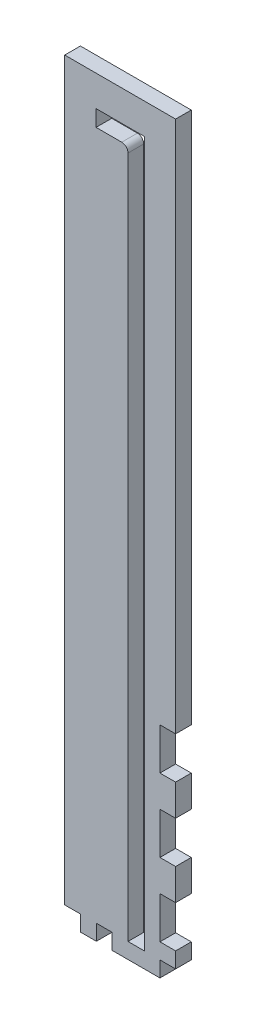
from build123d import *

# Parameters (mm, degrees)
SKETCH1_W           = 44.958
SKETCH1_H           = 304.8
BOSS_EXTRUDE1_DEPTH = 6.35
SKETCH2_W           = 6.35
SKETCH2_H           = 101.6
BOSS_EXTRUDE2_DEPTH = 6.35
SKETCH3_W           = 222.25
SKETCH3_H           = 6.35
BOSS_EXTRUDE3_DEPTH = 38.608
SKETCH7_W           = 327.022738736
SKETCH7_H           = 279.435650021
CUT_EXTRUDE1_DEPTH  = 45.958
SKETCH4_W           = 6.35
SKETCH4_H           = 6.35
SKETCH4_H_2         = 12.7
CUT_EXTRUDE2_DEPTH  = 6.35
SKETCH6_W           = 6.35
SKETCH6_H           = 16.933333333
SKETCH6_H_2         = 16.933333334
CUT_EXTRUDE3_DEPTH  = 7.35


with BuildPart() as part:
    # Sketch1 → Boss-Extrude1 (new body)
    with BuildSketch(Plane.XY):
        with Locations((-6.477, 3.048)):
            Rectangle(SKETCH1_W, SKETCH1_H)
        with BuildLine():
            Line((-3.302, 133.858), (-3.302, -143.002))
            Line((-3.302, -143.002), (3.302, -143.002))
            Line((3.302, -143.002), (3.302, 143.002))
            Line((3.302, 143.002), (-16.256, 143.002))
            Line((-16.256, 143.002), (-16.256, 136.398))
            Line((-16.256, 136.398), (-5.842, 136.398))
            ThreePointArc((-5.842, 136.398), (-4.045948776, 135.654051224), (-3.302, 133.858))
        make_face(mode=Mode.SUBTRACT)
    extrude(amount=BOSS_EXTRUDE1_DEPTH)

    # Sketch2 → Boss-Extrude2 (add)
    with BuildSketch(Plane(origin=(16.002, 0, 0), x_dir=(0, 0, -1), z_dir=(1, 0, 0))):
        Polygon((222.25, -60.452), (222.25, -47.752), (0, -47.752), (0, -149.352), (222.25, -149.352), (222.25, -136.652), (228.6, -136.652), (228.6, -119.718666667), (222.25, -119.718666667), (222.25, -107.018666667), (228.6, -107.018666667), (228.6, -90.085333333), (222.25, -90.085333333), (222.25, -77.385333333), (228.6, -77.385333333), (228.6, -60.452), align=None)
        with BuildLine():
            ThreePointArc((11.4, -116.592), (9.9, -118.092), (8.4, -116.592))
            Line((8.4, -116.592), (8.4, -111.512))
            ThreePointArc((8.4, -111.512), (9.9, -110.012), (11.4, -111.512))
            Line((11.4, -111.512), (11.4, -116.592))
        make_face(mode=Mode.SUBTRACT)
        with BuildLine():
            Line((42.4, -111.512), (42.4, -116.592))
            ThreePointArc((42.4, -116.592), (40.9, -118.092), (39.4, -116.592))
            Line((39.4, -116.592), (39.4, -111.512))
            ThreePointArc((39.4, -111.512), (40.9, -110.012), (42.4, -111.512))
        make_face(mode=Mode.SUBTRACT)
        with BuildLine():
            ThreePointArc((36.4, -101.092), (25.4, -112.092), (14.4, -101.092))
            Line((14.4, -101.092), (14.4, -96.012))
            ThreePointArc((14.4, -96.012), (25.4, -85.012), (36.4, -96.012))
            Line((36.4, -96.012), (36.4, -101.092))
        make_face(mode=Mode.SUBTRACT)
        with BuildLine():
            ThreePointArc((11.4, -85.592), (9.9, -87.092), (8.4, -85.592))
            Line((8.4, -85.592), (8.4, -80.512))
            ThreePointArc((8.4, -80.512), (9.9, -79.012), (11.4, -80.512))
            Line((11.4, -80.512), (11.4, -85.592))
        make_face(mode=Mode.SUBTRACT)
        with BuildLine():
            ThreePointArc((42.4, -85.592), (40.9, -87.092), (39.4, -85.592))
            Line((39.4, -85.592), (39.4, -80.512))
            ThreePointArc((39.4, -80.512), (40.9, -79.012), (42.4, -80.512))
            Line((42.4, -80.512), (42.4, -85.592))
        make_face(mode=Mode.SUBTRACT)
        with Locations((-3.175, -98.552)):
            Rectangle(SKETCH2_W, SKETCH2_H)
    extrude(amount=-BOSS_EXTRUDE2_DEPTH)

    # Sketch3 → Boss-Extrude3 (add)
    with BuildSketch(Plane.ZY.offset(-9.652)):
        with Locations((-111.125, -146.177)):
            Rectangle(SKETCH3_W, SKETCH3_H)
    extrude(amount=BOSS_EXTRUDE3_DEPTH)

    # Sketch7 → Cut-Extrude1 (cut, through all)
    with BuildSketch(Plane(origin=(16.002, 0, 0), x_dir=(0, 0, -1), z_dir=(1, 0, 0))):
        with Locations((163.511369368, -148.348068682)):
            Rectangle(SKETCH7_W, SKETCH7_H)
    extrude(amount=-CUT_EXTRUDE1_DEPTH, mode=Mode.SUBTRACT)

    # Sketch4 → Cut-Extrude2 (cut)
    with BuildSketch(Plane.XZ.offset(149.352)):
        with Locations((-12.954, 3.175)):
            Rectangle(SKETCH4_W, SKETCH4_H)
        with Locations((12.827, 3.175)):
            Rectangle(SKETCH4_W, SKETCH4_H)
        with Locations((-25.781, 3.175)):
            Rectangle(SKETCH4_W, SKETCH4_H)
        with Locations((12.827, -134.9375)):
            Rectangle(SKETCH4_W, SKETCH4_H_2)
        with Locations((12.827, -53.975)):
            Rectangle(SKETCH4_W, SKETCH4_H_2)
        with Locations((12.827, -161.925)):
            Rectangle(SKETCH4_W, SKETCH4_H_2)
    extrude(amount=-CUT_EXTRUDE2_DEPTH, mode=Mode.SUBTRACT)

    # Sketch6 → Cut-Extrude3 (cut, through all)
    with BuildSketch(Plane.XY.offset(6.35)):
        with Locations((12.827, -68.918666667)):
            Rectangle(SKETCH6_W, SKETCH6_H)
        with Locations((12.827, -98.552)):
            Rectangle(SKETCH6_W, SKETCH6_H_2)
        with Locations((12.827, -128.185333334)):
            Rectangle(SKETCH6_W, SKETCH6_H)
    extrude(amount=-CUT_EXTRUDE3_DEPTH, mode=Mode.SUBTRACT)


solid = part.part
